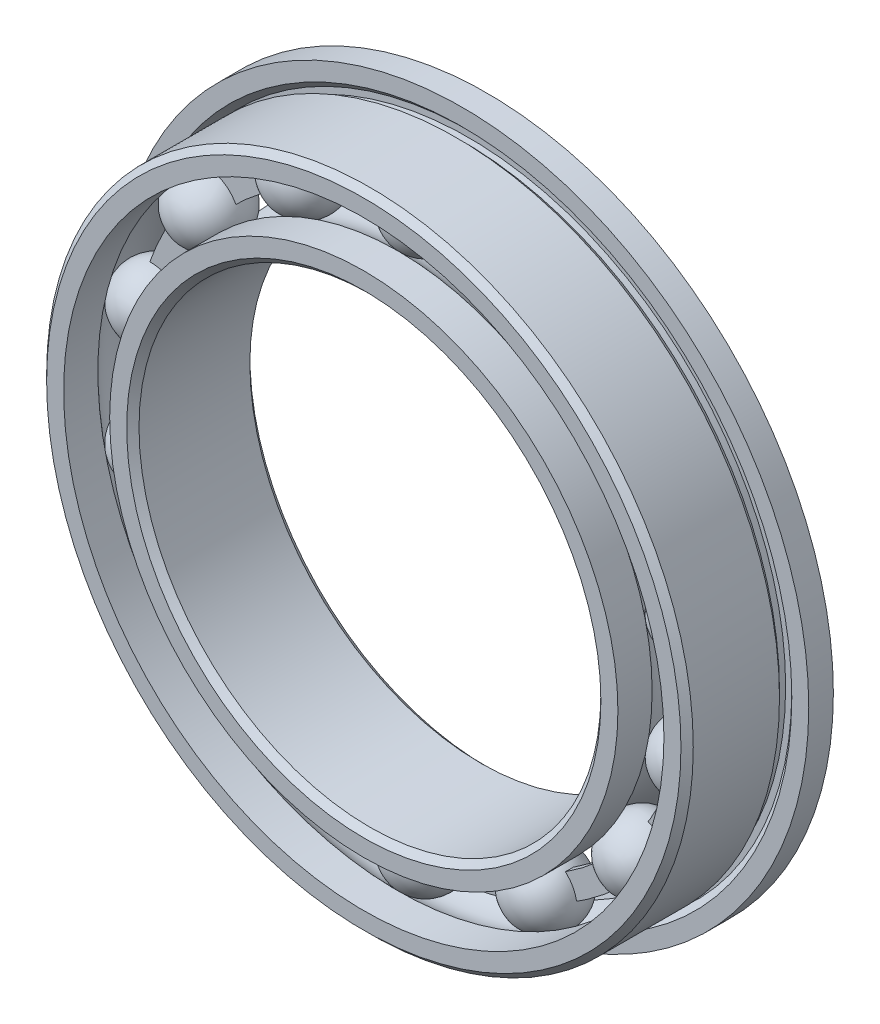
from build123d import *

# Parameters (mm, degrees)
SKETCH6_W         = 0.24908425
SKETCH6_H         = 0.747252748
CIRPATTERN1_COUNT = 14


with BuildPart() as part:
    # Sketch1 → Revolve1 (revolve)
    with BuildSketch(Plane(origin=(0, 0, 0), x_dir=(0, 0, -1), z_dir=(1, 0, 0))):
        with BuildLine():
            Line((-1.8, 10.5), (-2, 10.3))
            Line((-2, 10.3), (-2, 9.747252747))
            Line((-2, 9.747252747), (-0.888888889, 9.747252747))
            ThreePointArc((-0.888888889, 9.747252747), (0, 10.161253687), (0.888888889, 9.747252747))
            Line((0.888888889, 9.747252747), (2, 9.747252747))
            Line((2, 9.747252747), (2, 10.3))
            Line((2, 10.3), (2, 11.25))
            Line((2, 11.25), (1.2, 11.25))
            Line((1.2, 11.25), (1.2, 10.7))
            Line((1.2, 10.7), (1.4, 10.5))
            Line((1.4, 10.5), (1.4, 10.3))
            Line((1.4, 10.3), (1.2, 10.3))
            Line((1.2, 10.3), (1, 10.5))
            Line((1, 10.5), (-1.8, 10.5))
        make_face()
    revolve(axis=Axis((0, 0, 2), (0, 0, -1)))


with BuildPart() as body_2:
    # Sketch3 → Revolve3 (revolve)
    with BuildSketch(Plane(origin=(0, 0, 0), x_dir=(0, 0, -1), z_dir=(1, 0, 0))):
        with BuildLine():
            Line((-2, 8.252747253), (-0.888888889, 8.252747253))
            ThreePointArc((-0.888888889, 8.252747253), (0, 7.838746313), (0.888888889, 8.252747253))
            Line((0.888888889, 8.252747253), (2, 8.252747253))
            Line((2, 8.252747253), (2, 7.7))
            Line((2, 7.7), (1.8, 7.5))
            Line((1.8, 7.5), (-1.8, 7.5))
            Line((-1.8, 7.5), (-2, 7.7))
            Line((-2, 7.7), (-2, 8.252747253))
        make_face()
    revolve(axis=Axis((0, 0, 2), (0, 0, -1)))


with BuildPart() as body_3:
    # Sketch6 → Revolve6 (revolve)
    with BuildSketch(Plane(origin=(0, 0, 0), x_dir=(0, 0, -1), z_dir=(1, 0, 0))):
        with Locations((0, 9)):
            Rectangle(SKETCH6_W, SKETCH6_H)
    revolve(axis=Axis((0, 0, 2), (0, 0, -1)))


with BuildPart() as body_4:
    # Sketch4 → Revolve4 (revolve)
    with BuildSketch(Plane(origin=(0, 0, 0), x_dir=(0, 0, -1), z_dir=(1, 0, 0))):
        with BuildLine():
            Line((-1.161253687, 9), (1.161253687, 9))
            ThreePointArc((1.161253687, 9), (0, 10.161253687), (-1.161253687, 9))
        make_face()
    revolve(axis=Axis((0, 9, 1.161253687), (0, 0, -1)))


with BuildPart() as cirpattern1_1:
    # CirPattern1: pattern copy
    add(body_4.part.rotate(Axis((0, 0, -2), (0, 0, 1)), 1 * 360 / CIRPATTERN1_COUNT))


with BuildPart() as cirpattern1_2:
    # CirPattern1: pattern copy
    add(body_4.part.rotate(Axis((0, 0, -2), (0, 0, 1)), 2 * 360 / CIRPATTERN1_COUNT))


with BuildPart() as cirpattern1_3:
    # CirPattern1: pattern copy
    add(body_4.part.rotate(Axis((0, 0, -2), (0, 0, 1)), 3 * 360 / CIRPATTERN1_COUNT))


with BuildPart() as cirpattern1_4:
    # CirPattern1: pattern copy
    add(body_4.part.rotate(Axis((0, 0, -2), (0, 0, 1)), 4 * 360 / CIRPATTERN1_COUNT))


with BuildPart() as cirpattern1_5:
    # CirPattern1: pattern copy
    add(body_4.part.rotate(Axis((0, 0, -2), (0, 0, 1)), 5 * 360 / CIRPATTERN1_COUNT))


with BuildPart() as cirpattern1_6:
    # CirPattern1: pattern copy
    add(body_4.part.rotate(Axis((0, 0, -2), (0, 0, 1)), 6 * 360 / CIRPATTERN1_COUNT))


with BuildPart() as cirpattern1_7:
    # CirPattern1: pattern copy
    add(body_4.part.rotate(Axis((0, 0, -2), (0, 0, 1)), 7 * 360 / CIRPATTERN1_COUNT))


with BuildPart() as cirpattern1_8:
    # CirPattern1: pattern copy
    add(body_4.part.rotate(Axis((0, 0, -2), (0, 0, 1)), 8 * 360 / CIRPATTERN1_COUNT))


with BuildPart() as cirpattern1_9:
    # CirPattern1: pattern copy
    add(body_4.part.rotate(Axis((0, 0, -2), (0, 0, 1)), 9 * 360 / CIRPATTERN1_COUNT))


with BuildPart() as cirpattern1_10:
    # CirPattern1: pattern copy
    add(body_4.part.rotate(Axis((0, 0, -2), (0, 0, 1)), 10 * 360 / CIRPATTERN1_COUNT))


with BuildPart() as cirpattern1_11:
    # CirPattern1: pattern copy
    add(body_4.part.rotate(Axis((0, 0, -2), (0, 0, 1)), 11 * 360 / CIRPATTERN1_COUNT))


with BuildPart() as cirpattern1_12:
    # CirPattern1: pattern copy
    add(body_4.part.rotate(Axis((0, 0, -2), (0, 0, 1)), 12 * 360 / CIRPATTERN1_COUNT))


with BuildPart() as cirpattern1_13:
    # CirPattern1: pattern copy
    add(body_4.part.rotate(Axis((0, 0, -2), (0, 0, 1)), 13 * 360 / CIRPATTERN1_COUNT))


solid = Compound([part.part, body_2.part, body_3.part, body_4.part, cirpattern1_1.part, cirpattern1_2.part, cirpattern1_3.part, cirpattern1_4.part, cirpattern1_5.part, cirpattern1_6.part, cirpattern1_7.part, cirpattern1_8.part, cirpattern1_9.part, cirpattern1_10.part, cirpattern1_11.part, cirpattern1_12.part, cirpattern1_13.part])
